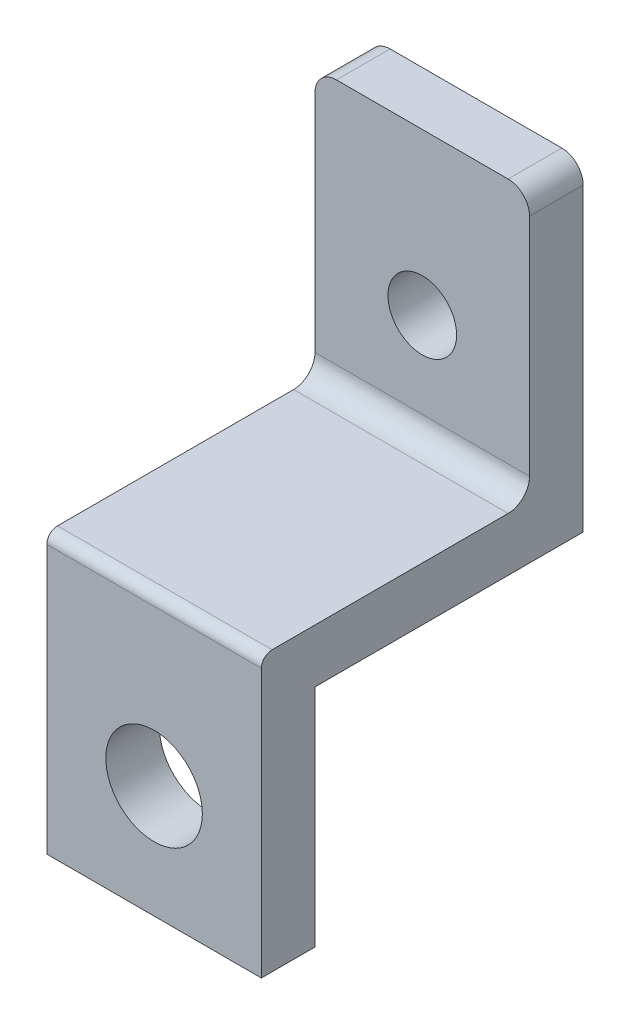
from build123d import *

# Parameters (mm, degrees)
SKETCH1_R           = 4.5
BOSS_EXTRUDE1_DEPTH = 5
SKETCH2_W           = 20
SKETCH2_H           = 39
BOSS_EXTRUDE2_DEPTH = 25
CUT_EXTRUDE1_DEPTH  = 30
SKETCH4_R           = 3.2
CUT_EXTRUDE2_DEPTH  = 10
FILLET1_R           = 2
FILLET2_R           = 1
SKETCH5_W           = 20
SKETCH5_H           = 9
CUT_EXTRUDE3_DEPTH  = 10
FILLET3_R           = 2


with BuildPart() as part:
    # Sketch1 → Boss-Extrude1 (new body)
    with BuildSketch(Plane.XY):
        Polygon((-10, 10), (-10, -10), (-10, -11), (10, -11), (10, -10), (10, 10), (10, 44), (-10, 44), align=None)
        with Locations((0, -0.5)):
            Circle(SKETCH1_R, mode=Mode.SUBTRACT)
    extrude(amount=BOSS_EXTRUDE1_DEPTH)

    # Sketch2 → Boss-Extrude2 (add)
    with BuildSketch(Plane(origin=(0, 0, 0), x_dir=(-1, 0, 0), z_dir=(0, 0, -1))):
        with Locations((0, 29.5)):
            Rectangle(SKETCH2_W, SKETCH2_H)
    extrude(amount=BOSS_EXTRUDE2_DEPTH)

    # Sketch3 → Cut-Extrude1 (cut)
    with BuildSketch(Plane(origin=(10, 0, 0), x_dir=(0, 0, -1), z_dir=(1, 0, 0))):
        Polygon((0, 15), (-5, 15), (-5, 49), (20, 49), (20, 15), align=None)
    extrude(amount=-CUT_EXTRUDE1_DEPTH, mode=Mode.SUBTRACT)

    # Sketch4 → Cut-Extrude2 (cut)
    with BuildSketch(Plane.XY.offset(-20)):
        with Locations((0, 25)):
            Circle(SKETCH4_R)
    extrude(amount=-CUT_EXTRUDE2_DEPTH, mode=Mode.SUBTRACT)

    # Fillet1
    fillet1_edges = [part.edges().sort_by_distance(p)[0] for p in [
        (0, 15, -20),
    ]]
    fillet(fillet1_edges, radius=FILLET1_R)

    # Fillet2
    fillet2_edges = [part.edges().sort_by_distance(p)[0] for p in [
        (0, 15, 5),
    ]]
    fillet(fillet2_edges, radius=FILLET2_R)

    # Sketch5 → Cut-Extrude3 (cut)
    with BuildSketch(Plane.XY.offset(-20)):
        with Locations((0, 44.5)):
            Rectangle(SKETCH5_W, SKETCH5_H)
    extrude(amount=-CUT_EXTRUDE3_DEPTH, mode=Mode.SUBTRACT)

    # Fillet3
    fillet3_edges = [part.edges().sort_by_distance(p)[0] for p in [
        (10, 40, -22.5),
        (-10, 40, -22.5),
    ]]
    fillet(fillet3_edges, radius=FILLET3_R)


solid = part.part
